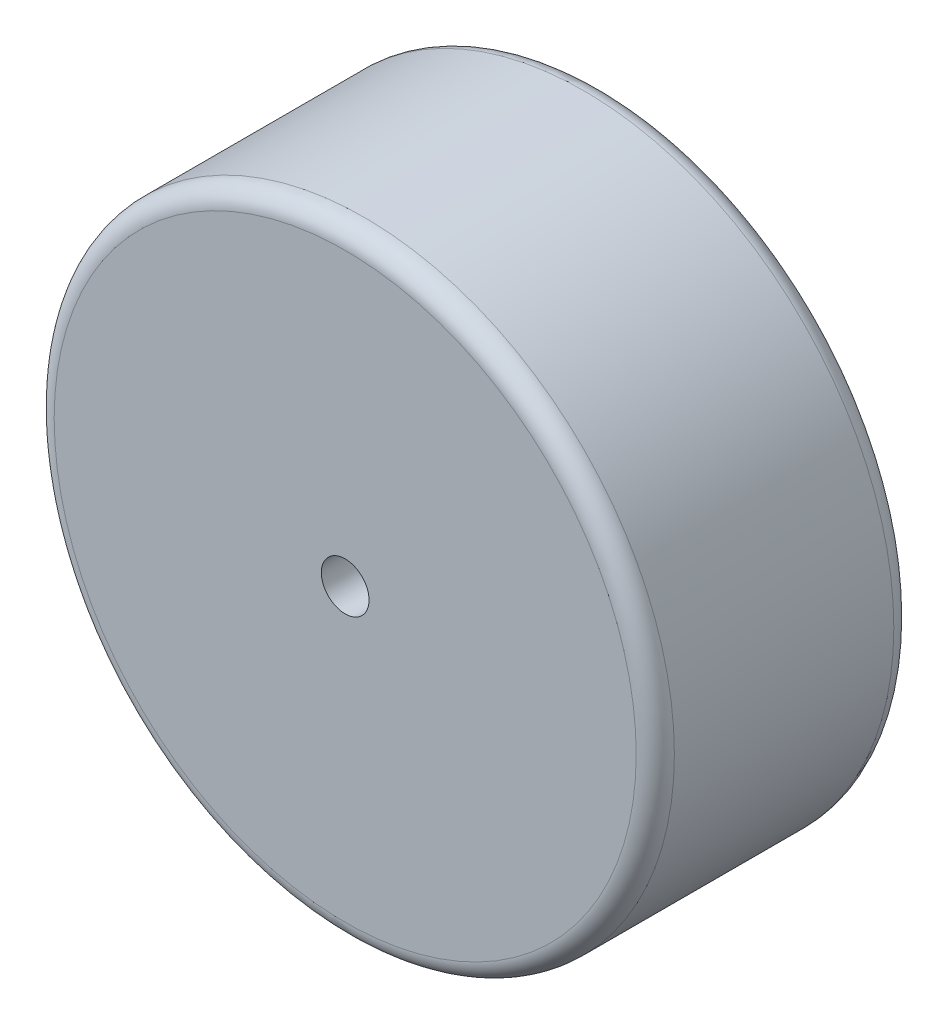
from build123d import *

# Parameters (mm, degrees)
SKETCH1_R           = 32.5
BOSS_EXTRUDE1_DEPTH = 13.5
FILLET1_R           = 2
SKETCH2_R           = 2.5
CUT_EXTRUDE1_DEPTH  = 28


with BuildPart() as part:
    # Sketch1 → Boss-Extrude1 (new body, symmetric)
    with BuildSketch(Plane.XY):
        Circle(SKETCH1_R)
    extrude(amount=BOSS_EXTRUDE1_DEPTH, both=True)

    # Fillet1
    fillet1_edges = [part.edges().sort_by_distance(p)[0] for p in [
        (-32.5, 0, -13.5),
        (-32.5, 0, 13.5),
    ]]
    fillet(fillet1_edges, radius=FILLET1_R)

    # Sketch2 → Cut-Extrude1 (cut, through all)
    with BuildSketch(Plane.XY.offset(13.5)):
        Circle(SKETCH2_R)
    extrude(amount=-CUT_EXTRUDE1_DEPTH, mode=Mode.SUBTRACT)


solid = part.part
